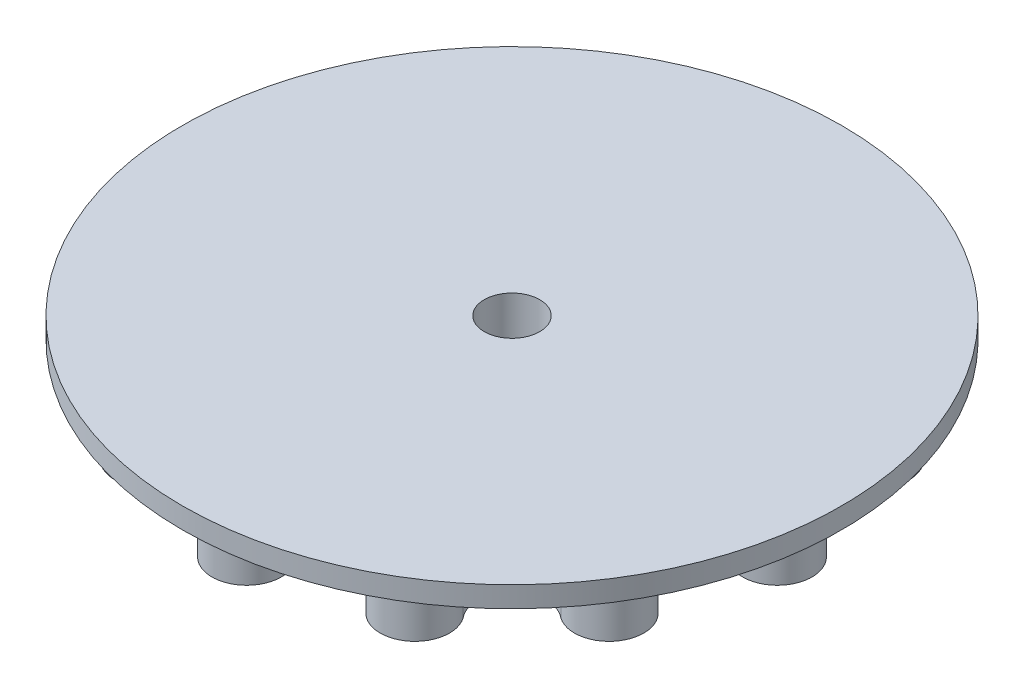
from build123d import *

# Parameters (mm, degrees)
BOSS_EXTRUDE1_DEPTH = 8
SKETCH3_R           = 47.5
BOSS_EXTRUDE2_DEPTH = 3
SKETCH4_R           = 4
CUT_EXTRUDE1_DEPTH  = 30


with BuildPart() as part:
    # Sketch1 → Boss-Extrude1 (new body)
    with BuildSketch(Plane(origin=(0, 0, 0), x_dir=(1, 0, 0), z_dir=(0, 1, 0))):
        with BuildLine():
            ThreePointArc((37.867444544, -4.985343651), (43.25, 0), (37.867444544, 4.985343651))
            ThreePointArc((37.867444544, 4.985343651), (32.117033724, 8.60573325), (35.286840777, 14.616288023))
            ThreePointArc((35.286840777, 14.616288023), (37.455598714, 21.625), (30.301497126, 23.251156521))
            ThreePointArc((30.301497126, 23.251156521), (23.511300474, 23.511300474), (23.251156521, 30.301497126))
            ThreePointArc((23.251156521, 30.301497126), (21.625, 37.455598714), (14.616288023, 35.286840777))
            ThreePointArc((14.616288023, 35.286840777), (8.60573325, 32.117033724), (4.985343651, 37.867444544))
            ThreePointArc((4.985343651, 37.867444544), (0, 43.25), (-4.985343651, 37.867444544))
            ThreePointArc((-4.985343651, 37.867444544), (-8.60573325, 32.117033724), (-14.616288023, 35.286840777))
            ThreePointArc((-14.616288023, 35.286840777), (-21.625, 37.455598714), (-23.251156521, 30.301497126))
            ThreePointArc((-23.251156521, 30.301497126), (-23.511300474, 23.511300474), (-30.301497126, 23.251156521))
            ThreePointArc((-30.301497126, 23.251156521), (-37.455598714, 21.625), (-35.286840777, 14.616288023))
            ThreePointArc((-35.286840777, 14.616288023), (-32.117033724, 8.60573325), (-37.867444544, 4.985343651))
            ThreePointArc((-37.867444544, 4.985343651), (-43.25, 0), (-37.867444544, -4.985343651))
            ThreePointArc((-37.867444544, -4.985343651), (-32.117033724, -8.60573325), (-35.286840777, -14.616288023))
            ThreePointArc((-35.286840777, -14.616288023), (-37.455598714, -21.625), (-30.301497126, -23.251156521))
            ThreePointArc((-30.301497126, -23.251156521), (-23.511300474, -23.511300474), (-23.251156521, -30.301497126))
            ThreePointArc((-23.251156521, -30.301497126), (-21.625, -37.455598714), (-14.616288023, -35.286840777))
            ThreePointArc((-14.616288023, -35.286840777), (-8.60573325, -32.117033724), (-4.985343651, -37.867444544))
            ThreePointArc((-4.985343651, -37.867444544), (0, -43.25), (4.985343651, -37.867444544))
            ThreePointArc((4.985343651, -37.867444544), (8.60573325, -32.117033724), (14.616288023, -35.286840777))
            ThreePointArc((14.616288023, -35.286840777), (21.625, -37.455598714), (23.251156521, -30.301497126))
            ThreePointArc((23.251156521, -30.301497126), (23.511300474, -23.511300474), (30.301497126, -23.251156521))
            ThreePointArc((30.301497126, -23.251156521), (37.455598714, -21.625), (35.286840777, -14.616288023))
            ThreePointArc((35.286840777, -14.616288023), (32.117033724, -8.60573325), (37.867444544, -4.985343651))
        make_face()
    extrude(amount=BOSS_EXTRUDE1_DEPTH)

    # Sketch3 → Boss-Extrude2 (add)
    with BuildSketch(Plane(origin=(0, 8, 0), x_dir=(1, 0, 0), z_dir=(0, 1, 0))):
        Circle(SKETCH3_R)
    extrude(amount=BOSS_EXTRUDE2_DEPTH)

    # Sketch4 → Cut-Extrude1 (cut)
    with BuildSketch(Plane(origin=(0, 11, 0), x_dir=(1, 0, 0), z_dir=(0, 1, 0))):
        Circle(SKETCH4_R)
    extrude(amount=-CUT_EXTRUDE1_DEPTH, mode=Mode.SUBTRACT)


solid = part.part
